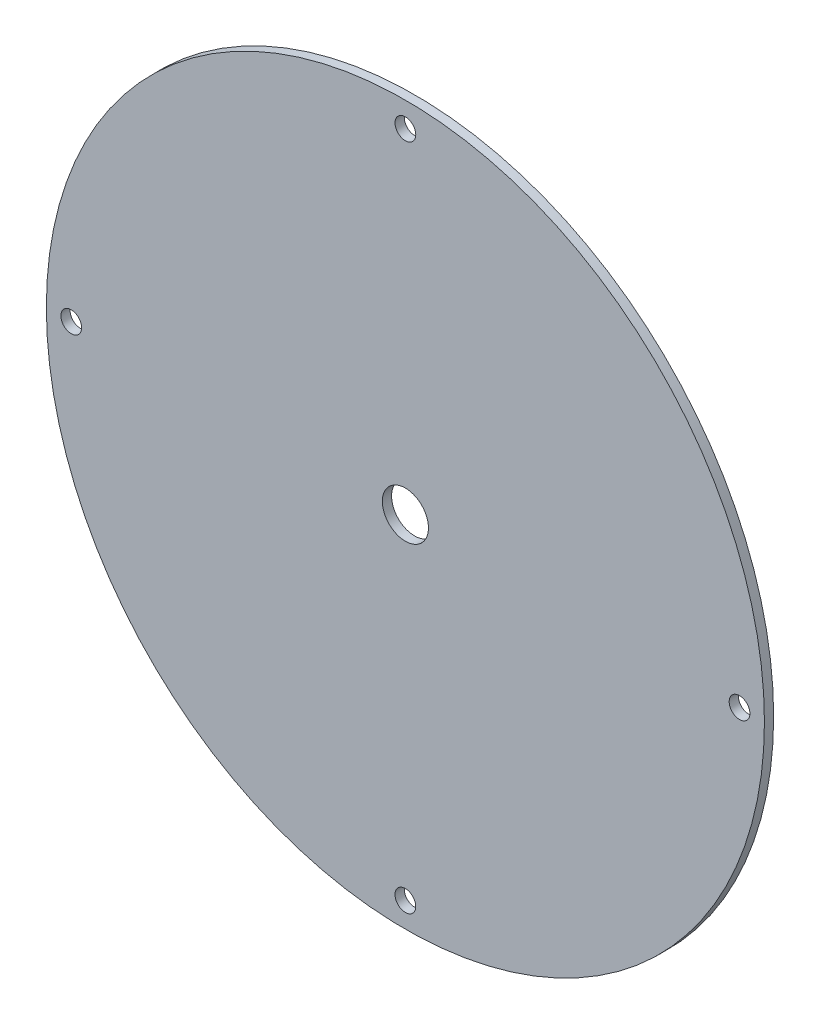
from build123d import *

# Parameters (mm, degrees)
ESQUISSE1_R        = 77.9
ESQUISSE1_R_2      = 2.25
ESQUISSE1_R_3      = 5
BOSS_EXTRU_1_DEPTH = 2


with BuildPart() as part:
    # Esquisse1 → Boss.-Extru.1 (new body)
    with BuildSketch(Plane.XY):
        with Locations((0.071120791, 0.517607885)):
            Circle(ESQUISSE1_R)
        with Locations((0.071120791, 73.017607885)):
            Circle(ESQUISSE1_R_2, mode=Mode.SUBTRACT)
        with Locations((72.571120791, 0.517607885)):
            Circle(ESQUISSE1_R_2, mode=Mode.SUBTRACT)
        with Locations((0.071120791, -71.982392115)):
            Circle(ESQUISSE1_R_2, mode=Mode.SUBTRACT)
        with Locations((-72.428879209, 0.517607885)):
            Circle(ESQUISSE1_R_2, mode=Mode.SUBTRACT)
        with Locations((0.071120791, 0.517607885)):
            Circle(ESQUISSE1_R_3, mode=Mode.SUBTRACT)
    extrude(amount=BOSS_EXTRU_1_DEPTH)


solid = part.part
